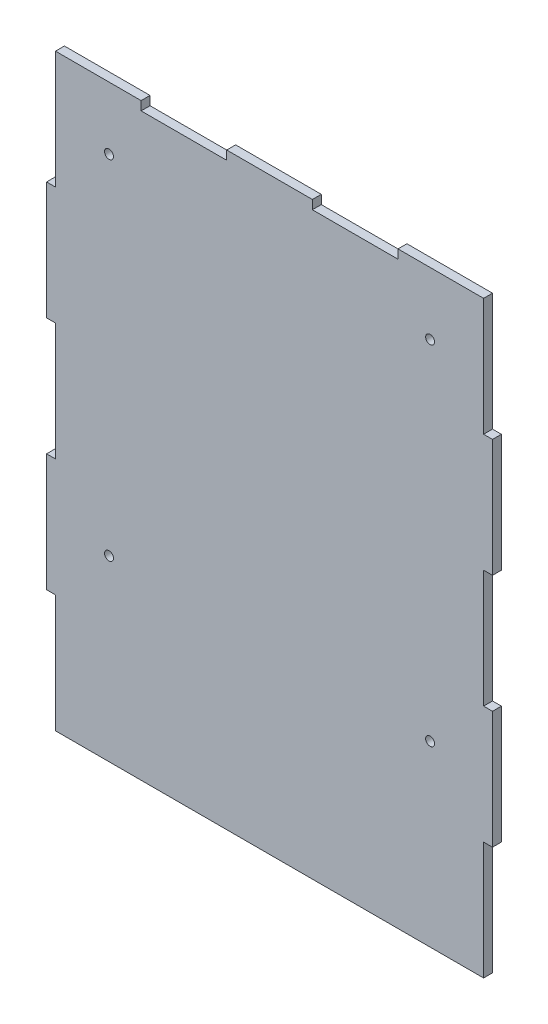
from build123d import *

# Parameters (mm, degrees)
BOSS_EXTRU_1_DEPTH                = 5
DIAM_TRE_DU_PER_AGE_5_0_5_1_D     = 5
DIAM_TRE_DU_PER_AGE_5_0_5_1_DEPTH = 5


with BuildPart() as part:
    # Esquisse1 → Boss.-Extru.1 (new body)
    with BuildSketch(Plane.XY):
        Polygon((0, 66), (5, 66), (5, 0), (245, 0), (245, 66), (250, 66), (250, 132), (245, 132), (245, 198), (250, 198), (250, 264), (245, 264), (245, 330), (197, 330), (197, 325), (149, 325), (149, 330), (101, 330), (101, 325), (53, 325), (53, 330), (5, 330), (5, 264), (0, 264), (0, 198), (5, 198), (5, 132), (0, 132), align=None)
    extrude(amount=BOSS_EXTRU_1_DEPTH)

    # Diamètre du perçage Ø5.0 (5)1
    with Locations(Plane.XY.offset(5)):
        with Locations((35, 295), (215, 295), (215, 100), (35, 100)):
            Hole(DIAM_TRE_DU_PER_AGE_5_0_5_1_D / 2, depth=DIAM_TRE_DU_PER_AGE_5_0_5_1_DEPTH)


solid = part.part
